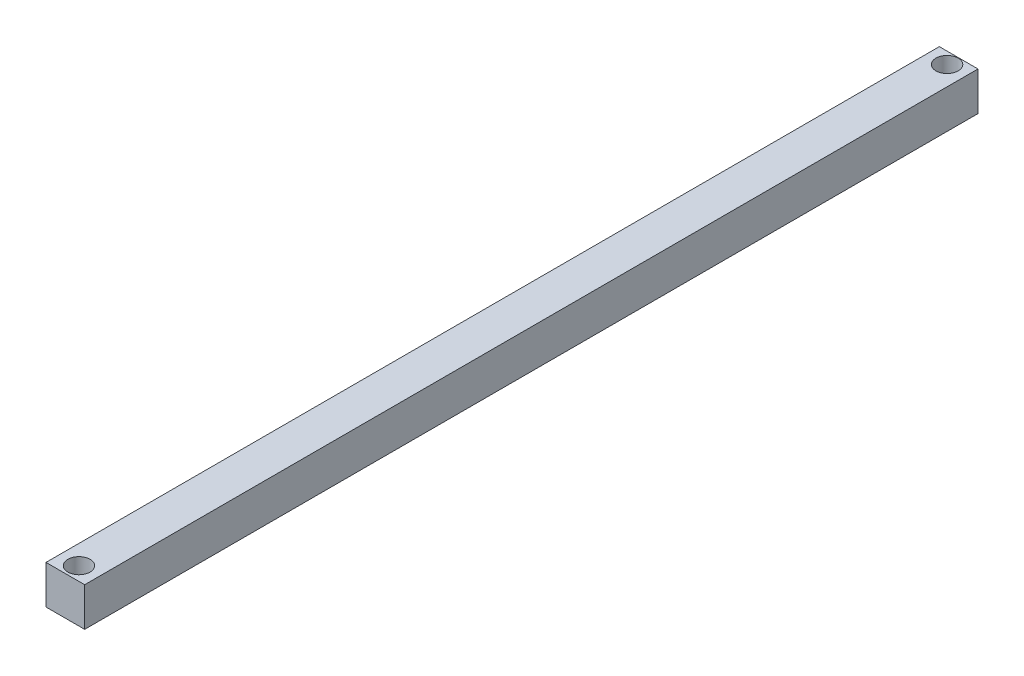
from build123d import *

# Parameters (mm, degrees)
SKETCH1_W           = 20
SKETCH1_H           = 462
BOSS_EXTRUDE1_DEPTH = 20
SKETCH3_R           = 5.75
CUT_EXTRUDE1_DEPTH  = 21


with BuildPart() as part:
    # Sketch1 → Boss-Extrude1 (new body)
    with BuildSketch(Plane(origin=(0, 0, 0), x_dir=(1, 0, 0), z_dir=(0, 1, 0))):
        Rectangle(SKETCH1_W, SKETCH1_H)
    extrude(amount=BOSS_EXTRUDE1_DEPTH)

    # Sketch3 → Cut-Extrude1 (cut, through all)
    with BuildSketch(Plane(origin=(0, 20, 0), x_dir=(1, 0, 0), z_dir=(0, 1, 0))):
        with Locations((0, 225)):
            Circle(SKETCH3_R)
        with Locations((0, -223.96)):
            Circle(SKETCH3_R)
    extrude(amount=-CUT_EXTRUDE1_DEPTH, mode=Mode.SUBTRACT)


solid = part.part
